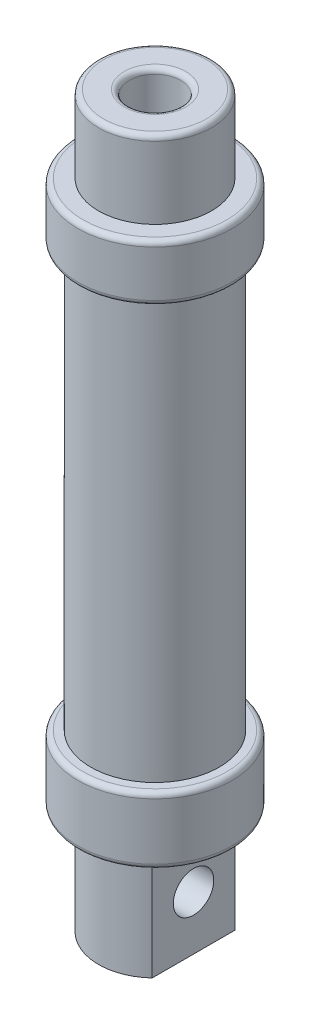
from build123d import *

# Parameters (mm, degrees)
SKETCH5_R                = 12.5
SKETCH5_R_2              = 10.5
BOSS_EXTRUDE2_DEPTH      = 84
SKETCH6_R                = 15
SKETCH6_R_2              = 11.543764588
BOSS_EXTRUDE3_DEPTH      = 10
BOSS_EXTRUDE3_DEPTH_BACK = 1
SKETCH7_R                = 15
SKETCH7_R_2              = 11.552767092
BOSS_EXTRUDE4_DEPTH      = 12
BOSS_EXTRUDE4_DEPTH_BACK = 1
FILLET1_R                = 1
FILLET2_R                = 1
FILLET3_R                = 1
FILLET4_R                = 1
SKETCH8_R                = 12.593226889
BOSS_EXTRUDE5_DEPTH      = 1
SKETCH9_R                = 12.737258032
BOSS_EXTRUDE6_DEPTH      = 1
SKETCH10_R               = 11
BOSS_EXTRUDE7_DEPTH      = 21
CUT_EXTRUDE1_DEPTH       = 21
SKETCH12_R               = 3.935
CUT_EXTRUDE2_DEPTH       = 23.5000001
SKETCH13_R               = 11
BOSS_EXTRUDE8_DEPTH      = 15
SKETCH14_R               = 5
CUT_EXTRUDE3_DEPTH       = 20
FILLET5_R                = 1
FILLET6_R                = 1


with BuildPart() as part:
    # Sketch5 → Boss-Extrude2 (new body)
    with BuildSketch(Plane(origin=(0, 0, 0), x_dir=(1, 0, 0), z_dir=(0, 1, 0))):
        Circle(SKETCH5_R)
        Circle(SKETCH5_R_2, mode=Mode.SUBTRACT)
    extrude(amount=BOSS_EXTRUDE2_DEPTH)

    # Sketch6 → Boss-Extrude3 (add, two sides)
    with BuildSketch(Plane(origin=(0, 84, 0), x_dir=(1, 0, 0), z_dir=(0, 1, 0))) as boss_extrude3_sk:
        Circle(SKETCH6_R)
        Circle(SKETCH6_R_2, mode=Mode.SUBTRACT)
    extrude(amount=BOSS_EXTRUDE3_DEPTH)
    extrude(boss_extrude3_sk.sketch, amount=-BOSS_EXTRUDE3_DEPTH_BACK)

    # Sketch7 → Boss-Extrude4 (add, two sides)
    with BuildSketch(Plane.XZ) as boss_extrude4_sk:
        Circle(SKETCH7_R)
        Circle(SKETCH7_R_2, mode=Mode.SUBTRACT)
    extrude(amount=BOSS_EXTRUDE4_DEPTH)
    extrude(boss_extrude4_sk.sketch, amount=-BOSS_EXTRUDE4_DEPTH_BACK)

    # Fillet1
    fillet1_edges = [part.edges().sort_by_distance(p)[0] for p in [
        (-15, 83, 0),
    ]]
    fillet(fillet1_edges, radius=FILLET1_R)

    # Fillet2
    fillet2_edges = [part.edges().sort_by_distance(p)[0] for p in [
        (-15, 1, 0),
    ]]
    fillet(fillet2_edges, radius=FILLET2_R)

    # Fillet3
    fillet3_edges = [part.edges().sort_by_distance(p)[0] for p in [
        (-15, 94, 0),
    ]]
    fillet(fillet3_edges, radius=FILLET3_R)

    # Fillet4
    fillet4_edges = [part.edges().sort_by_distance(p)[0] for p in [
        (-15, -12, 0),
    ]]
    fillet(fillet4_edges, radius=FILLET4_R)

    # Sketch8 → Boss-Extrude5 (add)
    with BuildSketch(Plane(origin=(0, 94, 0), x_dir=(1, 0, 0), z_dir=(0, 1, 0))):
        Circle(SKETCH8_R)
    extrude(amount=-BOSS_EXTRUDE5_DEPTH)

    # Sketch9 → Boss-Extrude6 (add)
    with BuildSketch(Plane.XZ.offset(12)):
        Circle(SKETCH9_R)
    extrude(amount=-BOSS_EXTRUDE6_DEPTH)

    # Sketch10 → Boss-Extrude7 (add)
    with BuildSketch(Plane.XZ.offset(12)):
        Circle(SKETCH10_R)
    extrude(amount=BOSS_EXTRUDE7_DEPTH)

    # Sketch11 → Cut-Extrude1 (cut)
    with BuildSketch(Plane.XZ.offset(33)):
        with BuildLine():
            Line((-7.5, 8.04673847), (-7.5, 0))
            Line((-7.5, 0), (-7.5, -8.04673847))
            ThreePointArc((-7.5, -8.04673847), (-11, 0), (-7.5, 8.04673847))
        make_face()
        with BuildLine():
            Line((7.5, 0), (7.5, -8.04673847))
            ThreePointArc((7.5, -8.04673847), (11, 0), (7.5, 8.04673847))
            Line((7.5, 8.04673847), (7.5, 0))
        make_face()
    extrude(amount=-CUT_EXTRUDE1_DEPTH, mode=Mode.SUBTRACT)

    # Sketch12 → Cut-Extrude2 (cut, through all)
    with BuildSketch(Plane.ZY.offset(7.5)):
        with Locations((0, -22.5)):
            Circle(SKETCH12_R)
    extrude(amount=-CUT_EXTRUDE2_DEPTH, mode=Mode.SUBTRACT)

    # Sketch13 → Boss-Extrude8 (add)
    with BuildSketch(Plane(origin=(0, 94, 0), x_dir=(1, 0, 0), z_dir=(0, 1, 0))):
        Circle(SKETCH13_R)
    extrude(amount=BOSS_EXTRUDE8_DEPTH)

    # Sketch14 → Cut-Extrude3 (cut)
    with BuildSketch(Plane(origin=(0, 109, 0), x_dir=(1, 0, 0), z_dir=(0, 1, 0))):
        Circle(SKETCH14_R)
    extrude(amount=-CUT_EXTRUDE3_DEPTH, mode=Mode.SUBTRACT)

    # Fillet5
    fillet5_edges = [part.edges().sort_by_distance(p)[0] for p in [
        (-11, 109, 0),
    ]]
    fillet(fillet5_edges, radius=FILLET5_R)

    # Fillet6
    fillet6_edges = [part.edges().sort_by_distance(p)[0] for p in [
        (-5, 109, 0),
    ]]
    fillet(fillet6_edges, radius=FILLET6_R)


solid = part.part
